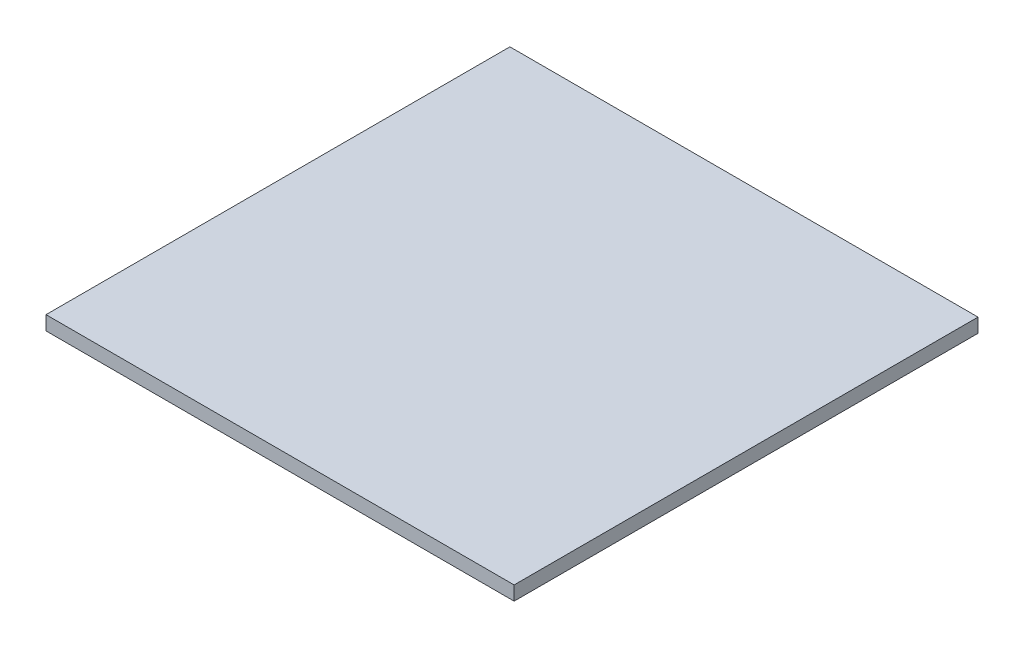
from build123d import *

# Parameters (mm, degrees)
SKETCH1_W           = 99.7
SKETCH1_H           = 98.8
BOSS_EXTRUDE1_DEPTH = 3


with BuildPart() as part:
    # Sketch1 → Boss-Extrude1 (new body)
    with BuildSketch(Plane(origin=(0, 0, 0), x_dir=(1, 0, 0), z_dir=(0, 1, 0))):
        with Locations((5.568457944, -28.701985981)):
            Rectangle(SKETCH1_W, SKETCH1_H)
    extrude(amount=BOSS_EXTRUDE1_DEPTH)


solid = part.part
